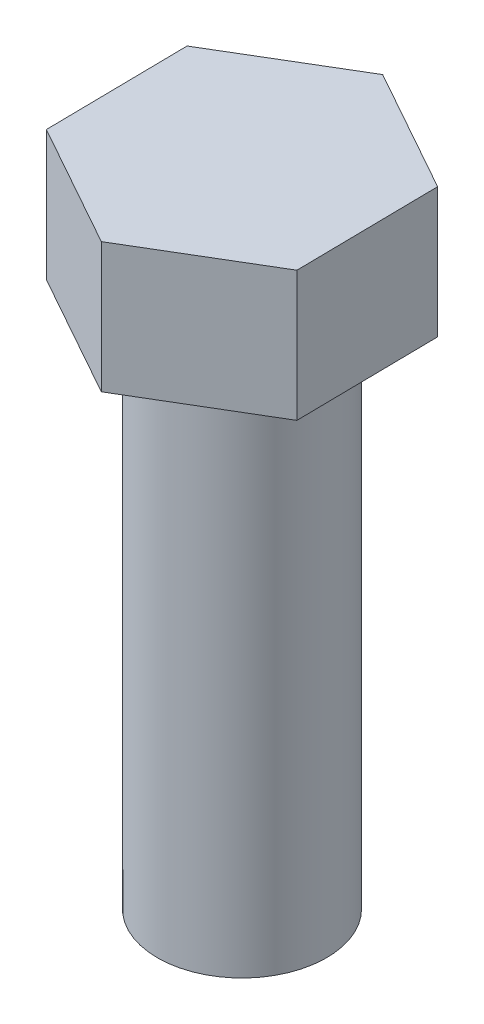
from build123d import *

# Parameters (mm, degrees)
SKETCH_2_R      = 6.5
EXTRUDE_1_DEPTH = 40
EXTRUDE_2_DEPTH = 10


with BuildPart() as part:
    # Эскиз2 → Бобышка-Вытянуть1 (new body)
    with BuildSketch(Plane(origin=(0, 0, 0), x_dir=(1, 0, 0), z_dir=(0, 1, 0))):
        Circle(SKETCH_2_R)
    extrude(amount=EXTRUDE_1_DEPTH)

    # Эскиз3 → Бобышка-Вытянуть2 (add)
    with BuildSketch(Plane(origin=(0, 40, 0), x_dir=(1, 0, 0), z_dir=(0, 1, 0))):
        Polygon((-9.575544284, 5.351848745), (-9.422609113, -5.616740233), (0.152935172, -10.968588978), (9.575544284, -5.351848745), (9.422609113, 5.616740233), (-0.152935172, 10.968588978), align=None)
    extrude(amount=EXTRUDE_2_DEPTH)


solid = part.part
